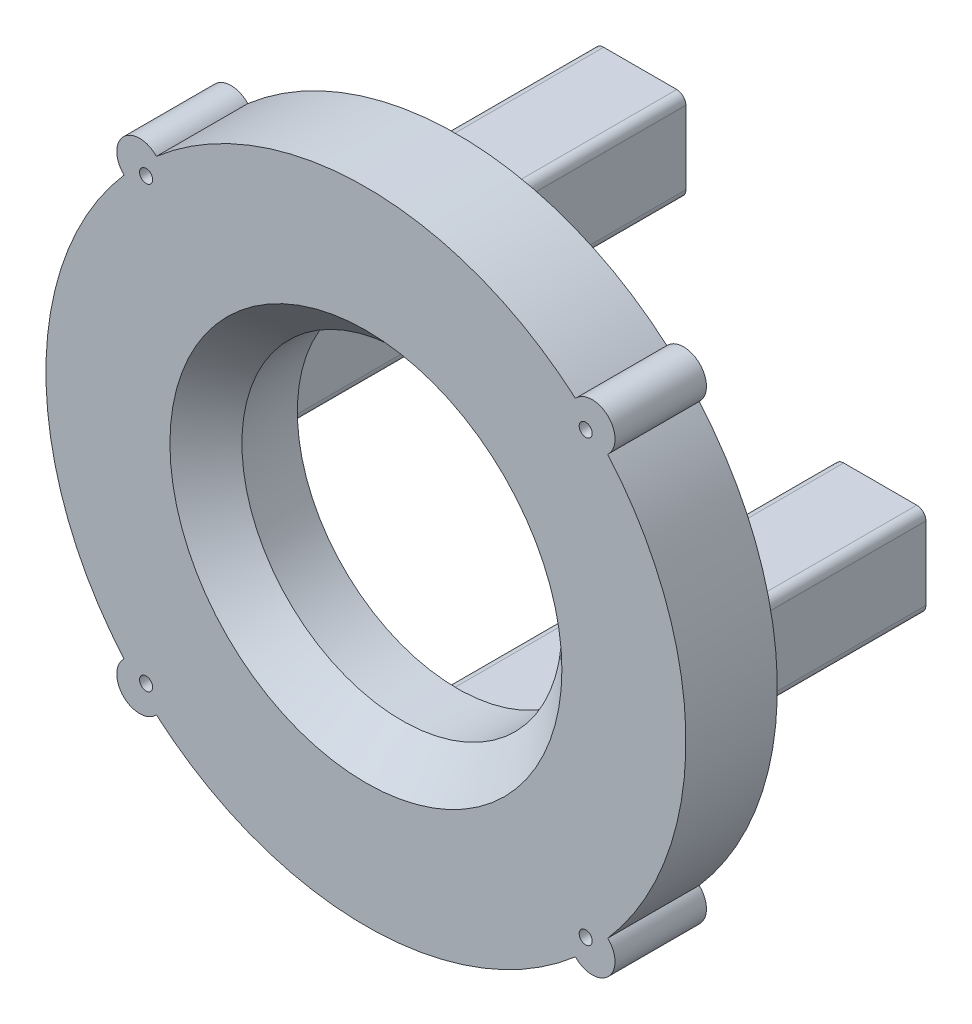
from build123d import *

# Parameters (mm, degrees)
SKETCH1_R           = 44.45
BOSS_EXTRUDE1_DEPTH = 25.4
CHAMFER1_SIZE       = 10
SKETCH3_R           = 1.8161
CUT_EXTRUDE1_DEPTH  = 26.4
BOSS_EXTRUDE3_DEPTH = 50.8


with BuildPart() as part:
    # Sketch1 → Boss-Extrude1 (new body)
    with BuildSketch(Plane.XY):
        with BuildLine():
            ThreePointArc((67.188694676, -58.214167586), (88.9, 0), (67.188694676, 58.214167586))
            ThreePointArc((67.188694676, 58.214167586), (67.351920908, 67.351920908), (58.214167586, 67.188694676))
            ThreePointArc((58.214167586, 67.188694676), (0, 88.9), (-58.214167586, 67.188694676))
            ThreePointArc((-58.214167586, 67.188694676), (-67.351920908, 67.351920908), (-67.188694676, 58.214167586))
            ThreePointArc((-67.188694676, 58.214167586), (-88.9, 0), (-67.188694676, -58.214167586))
            ThreePointArc((-67.188694676, -58.214167586), (-67.351920908, -67.351920908), (-58.214167586, -67.188694676))
            ThreePointArc((-58.214167586, -67.188694676), (0, -88.9), (58.214167586, -67.188694676))
            ThreePointArc((58.214167586, -67.188694676), (67.351920908, -67.351920908), (67.188694676, -58.214167586))
        make_face()
        Circle(SKETCH1_R, mode=Mode.SUBTRACT)
    extrude(amount=BOSS_EXTRUDE1_DEPTH)

    # Chamfer1
    chamfer1_edges = [part.edges().sort_by_distance(p)[0] for p in [
        (-44.45, 0, 25.4),
    ]]
    chamfer(chamfer1_edges, length=CHAMFER1_SIZE)

    # Sketch3 → Cut-Extrude1 (cut, through all)
    with BuildSketch(Plane.XY.offset(25.4)):
        with Locations((61.065741623, 61.065741623)):
            Circle(SKETCH3_R)
        with Locations((61.065741623, -61.065741623)):
            Circle(SKETCH3_R)
        with Locations((-61.065741623, -61.065741623)):
            Circle(SKETCH3_R)
        with Locations((-61.065741623, 61.065741623)):
            Circle(SKETCH3_R)
    extrude(amount=-CUT_EXTRUDE1_DEPTH, mode=Mode.SUBTRACT)

    # Sketch5 → Boss-Extrude3 (add)
    with BuildSketch(Plane(origin=(0, 0, 0), x_dir=(-1, 0, 0), z_dir=(0, 0, -1))):
        with BuildLine():
            Line((-76.835, 12.7), (-56.515, 12.7))
            ThreePointArc((-56.515, 12.7), (-54.718948776, 11.956051224), (-53.975, 10.16))
            Line((-53.975, 10.16), (-53.975, -10.16))
            ThreePointArc((-53.975, -10.16), (-54.718948776, -11.956051224), (-56.515, -12.7))
            Line((-56.515, -12.7), (-76.835, -12.7))
            ThreePointArc((-76.835, -12.7), (-78.631051224, -11.956051224), (-79.375, -10.16))
            Line((-79.375, -10.16), (-79.375, 10.16))
            ThreePointArc((-79.375, 10.16), (-78.631051224, 11.956051224), (-76.835, 12.7))
        make_face()
        with BuildLine():
            Line((-10.16, -79.375), (10.16, -79.375))
            ThreePointArc((10.16, -79.375), (11.956051224, -78.631051224), (12.7, -76.835))
            Line((12.7, -76.835), (12.7, -56.515))
            ThreePointArc((12.7, -56.515), (11.956051224, -54.718948776), (10.16, -53.975))
            Line((10.16, -53.975), (-10.16, -53.975))
            ThreePointArc((-10.16, -53.975), (-11.956051224, -54.718948776), (-12.7, -56.515))
            Line((-12.7, -56.515), (-12.7, -76.835))
            ThreePointArc((-12.7, -76.835), (-11.956051224, -78.631051224), (-10.16, -79.375))
        make_face()
        with BuildLine():
            Line((12.7, 76.835), (12.7, 56.515))
            ThreePointArc((12.7, 56.515), (11.956051224, 54.718948776), (10.16, 53.975))
            Line((10.16, 53.975), (-10.16, 53.975))
            ThreePointArc((-10.16, 53.975), (-11.956051224, 54.718948776), (-12.7, 56.515))
            Line((-12.7, 56.515), (-12.7, 76.835))
            ThreePointArc((-12.7, 76.835), (-11.956051224, 78.631051224), (-10.16, 79.375))
            Line((-10.16, 79.375), (10.16, 79.375))
            ThreePointArc((10.16, 79.375), (11.956051224, 78.631051224), (12.7, 76.835))
        make_face()
        with BuildLine():
            Line((76.835, -12.7), (56.515, -12.7))
            ThreePointArc((56.515, -12.7), (54.718948776, -11.956051224), (53.975, -10.16))
            Line((53.975, -10.16), (53.975, 10.16))
            ThreePointArc((53.975, 10.16), (54.718948776, 11.956051224), (56.515, 12.7))
            Line((56.515, 12.7), (76.835, 12.7))
            ThreePointArc((76.835, 12.7), (78.631051224, 11.956051224), (79.375, 10.16))
            Line((79.375, 10.16), (79.375, -10.16))
            ThreePointArc((79.375, -10.16), (78.631051224, -11.956051224), (76.835, -12.7))
        make_face()
    extrude(amount=BOSS_EXTRUDE3_DEPTH)


solid = part.part
